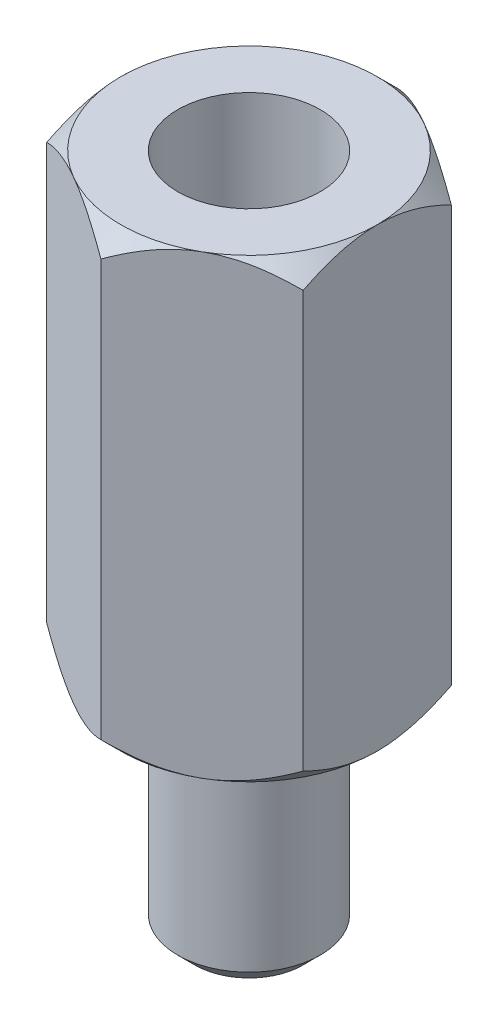
from build123d import *

# Parameters (mm, degrees)
SKETCH1_R           = 1.25
BOSS_EXTRUDE1_DEPTH = 3.9
BOSS_EXTRUDE2_DEPTH = 8
SKETCH3_R           = 1.25
CUT_EXTRUDE1_DEPTH  = 4.8
SKETCH5_OUTSIDE_W   = 35.048
SKETCH5_OUTSIDE_H   = 35.744
SKETCH5_OUTSIDE_R   = 2.25
CUT_EXTRUDE2_DEPTH  = 12.9
CUT_EXTRUDE2_TAPER  = 45
SKETCH6_OUTSIDE_W   = 27.248
SKETCH6_OUTSIDE_H   = 27.944
SKETCH6_OUTSIDE_R   = 2.25
CUT_EXTRUDE3_DEPTH  = 9
CUT_EXTRUDE3_TAPER  = 45
CHAMFER1_SIZE       = 0.3


with BuildPart() as part:
    # Sketch1 → Boss-Extrude1 (new body)
    with BuildSketch(Plane(origin=(0, 0, 0), x_dir=(1, 0, 0), z_dir=(0, 1, 0))):
        Circle(SKETCH1_R)
    extrude(amount=BOSS_EXTRUDE1_DEPTH)

    # Sketch2 → Boss-Extrude2 (add)
    with BuildSketch(Plane(origin=(0, 3.9, 0), x_dir=(1, 0, 0), z_dir=(0, 1, 0))):
        Polygon((0, 2.598076211), (-2.25, 1.299038106), (-2.25, -1.299038106), (0, -2.598076211), (2.25, -1.299038106), (2.25, 1.299038106), align=None)
    extrude(amount=BOSS_EXTRUDE2_DEPTH)

    # Sketch3 → Cut-Extrude1 (cut)
    with BuildSketch(Plane(origin=(0, 11.9, 0), x_dir=(1, 0, 0), z_dir=(0, 1, 0))):
        Circle(SKETCH3_R)
    extrude(amount=-CUT_EXTRUDE1_DEPTH, mode=Mode.SUBTRACT)

    # Sketch5 outside → Cut-Extrude2 (cut, through all)
    with BuildSketch(Plane(origin=(0, 11.9, 0), x_dir=(1, 0, 0), z_dir=(0, 1, 0))):
        Rectangle(SKETCH5_OUTSIDE_W, SKETCH5_OUTSIDE_H)
        Circle(SKETCH5_OUTSIDE_R, mode=Mode.SUBTRACT)
    extrude(amount=-CUT_EXTRUDE2_DEPTH, taper=CUT_EXTRUDE2_TAPER, mode=Mode.SUBTRACT)

    # Sketch6 outside → Cut-Extrude3 (cut, through all)
    with BuildSketch(Plane.XZ.offset(-3.9)):
        Rectangle(SKETCH6_OUTSIDE_W, SKETCH6_OUTSIDE_H)
        Circle(SKETCH6_OUTSIDE_R, mode=Mode.SUBTRACT)
    extrude(amount=-CUT_EXTRUDE3_DEPTH, taper=CUT_EXTRUDE3_TAPER, mode=Mode.SUBTRACT)

    # Chamfer1
    chamfer1_edges = [part.edges().sort_by_distance(p)[0] for p in [
        (-1.25, 0, 0),
    ]]
    chamfer(chamfer1_edges, length=CHAMFER1_SIZE)


solid = part.part
